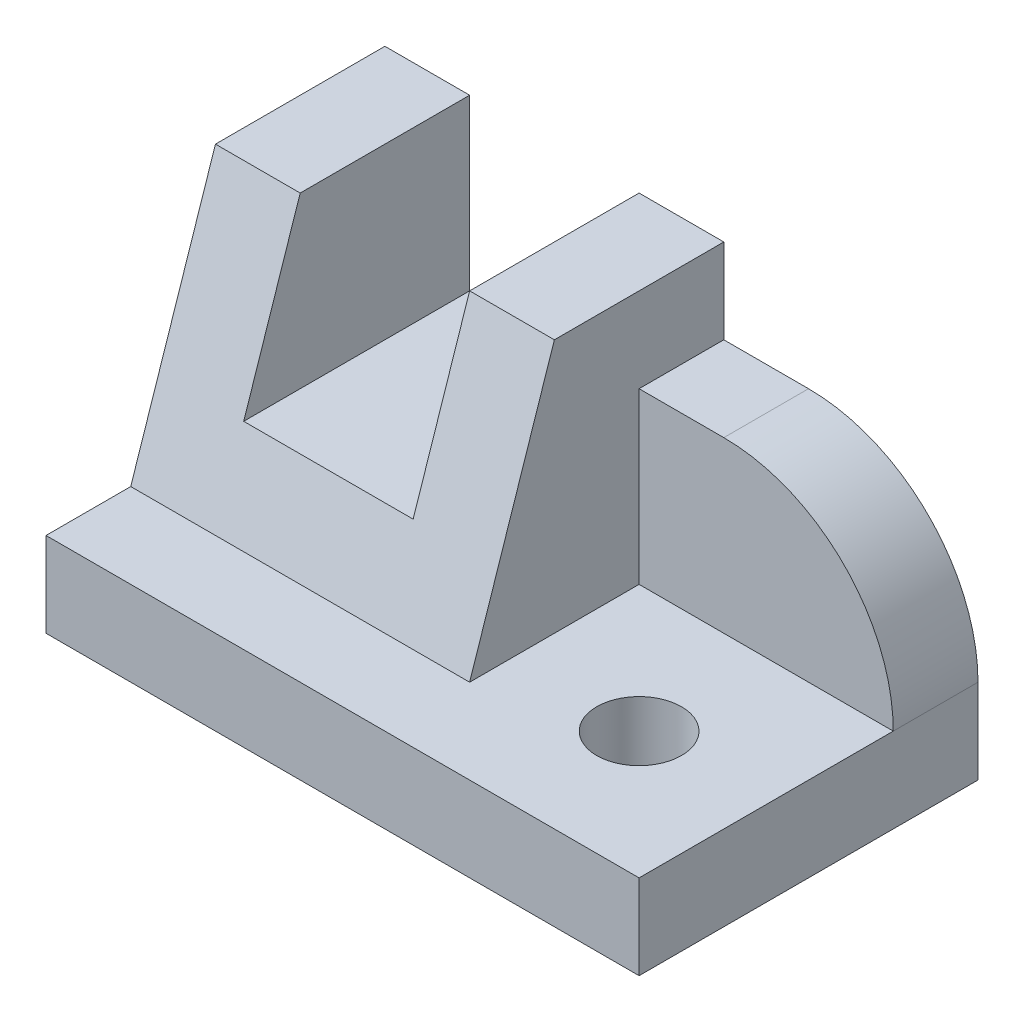
from build123d import *

# Parameters (mm, degrees)
BOSS_EXTRUDE1_DEPTH            = 40
SKETCH2_W                      = 40
SKETCH2_H                      = 30
BOSS_EXTRUDE2_DEPTH            = 20
BOSS_EXTRUDE3_DEPTH            = 30
CUT_EXTRUDE1_DEPTH             = 30
SKETCH5_W                      = 70
SKETCH5_H                      = 40
BOSS_EXTRUDE4_DEPTH            = 10
SKETCH6_W                      = 20
SKETCH6_H                      = 20
CUT_EXTRUDE2_DEPTH             = 41
F_10_0_10_DIAMETER_HOLE1_D     = 10
F_10_0_10_DIAMETER_HOLE1_DEPTH = 40
FILLET1_R                      = 20


with BuildPart() as part:
    # Sketch1 → Boss-Extrude1 (new body)
    with BuildSketch(Plane(origin=(0, 0, 0), x_dir=(0, -1, 0), z_dir=(-1, 0, 0))):
        Polygon((-10, -10), (-40, -20), (-10, -20), align=None)
    extrude(amount=-BOSS_EXTRUDE1_DEPTH)

    # Sketch2 → Boss-Extrude2 (add)
    with BuildSketch(Plane(origin=(0, 0, -20), x_dir=(-1, 0, 0), z_dir=(0, 0, -1))):
        with Locations((-20, 25)):
            Rectangle(SKETCH2_W, SKETCH2_H)
    extrude(amount=BOSS_EXTRUDE2_DEPTH)

    # Sketch3 → Boss-Extrude3 (add)
    with BuildSketch(Plane(origin=(40, 0, 0), x_dir=(0, 0, -1), z_dir=(1, 0, 0))):
        Polygon((40, 10), (0, 10), (20, 40), (40, 40), align=None)
    extrude(amount=BOSS_EXTRUDE3_DEPTH)

    # Sketch4 → Cut-Extrude1 (cut)
    with BuildSketch(Plane(origin=(70, 0, 0), x_dir=(0, 0, -1), z_dir=(1, 0, 0))):
        Polygon((20, 40), (0, 10), (30, 10), (30, 30), (40, 30), (40, 40), align=None)
    extrude(amount=-CUT_EXTRUDE1_DEPTH, mode=Mode.SUBTRACT)

    # Sketch5 → Boss-Extrude4 (add)
    with BuildSketch(Plane.XZ.offset(-10)):
        with Locations((35, -20)):
            Rectangle(SKETCH5_W, SKETCH5_H)
    extrude(amount=BOSS_EXTRUDE4_DEPTH)

    # Sketch6 → Cut-Extrude2 (cut, through all)
    with BuildSketch(Plane(origin=(0, 0, -40), x_dir=(-1, 0, 0), z_dir=(0, 0, -1))):
        with Locations((-20, 30)):
            Rectangle(SKETCH6_W, SKETCH6_H)
    extrude(amount=-CUT_EXTRUDE2_DEPTH, mode=Mode.SUBTRACT)

    # Ø10.0 (10) Diameter Hole1
    with Locations(Plane(origin=(0, 0, 0), x_dir=(-1, 0, 0), z_dir=(0, -1, 0))):
        with Locations((-55, 15)):
            Hole(F_10_0_10_DIAMETER_HOLE1_D / 2, depth=F_10_0_10_DIAMETER_HOLE1_DEPTH)

    # Fillet1
    fillet1_edges = [part.edges().sort_by_distance(p)[0] for p in [
        (70, 30, -35),
    ]]
    fillet(fillet1_edges, radius=FILLET1_R)


solid = part.part
